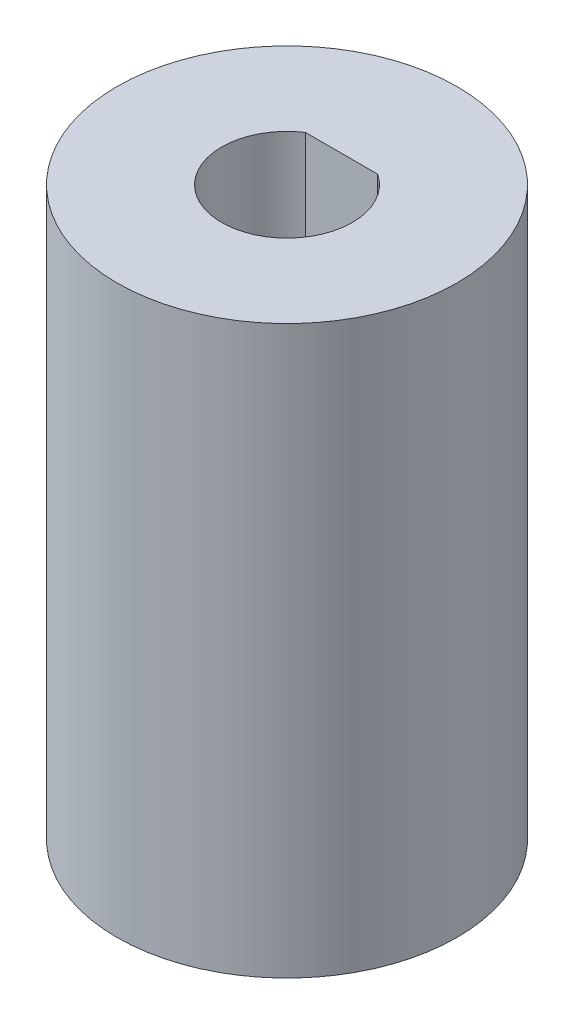
from build123d import *

# Parameters (mm, degrees)
SKETCH1_R           = 7.8
BOSS_EXTRUDE1_DEPTH = 26
CUT_EXTRUDE3_DEPTH  = 27


with BuildPart() as part:
    # Sketch1 → Boss-Extrude1 (new body)
    with BuildSketch(Plane(origin=(0, 0, 0), x_dir=(1, 0, 0), z_dir=(0, 1, 0))):
        Circle(SKETCH1_R)
    extrude(amount=BOSS_EXTRUDE1_DEPTH)

    # Sketch2 → Cut-Extrude3 (cut, through all)
    with BuildSketch(Plane(origin=(0, 0, 0), x_dir=(1, 0, 0), z_dir=(0, 1, 0))):
        with BuildLine():
            Line((1.658312395, 2.5), (-1.658312395, 2.5))
            ThreePointArc((-1.658312395, 2.5), (-1.418637165, -2.643382037), (3, 0))
            ThreePointArc((3, 0), (2.643382037, 1.418637165), (1.658312395, 2.5))
        make_face()
    extrude(amount=CUT_EXTRUDE3_DEPTH, mode=Mode.SUBTRACT)


solid = part.part
